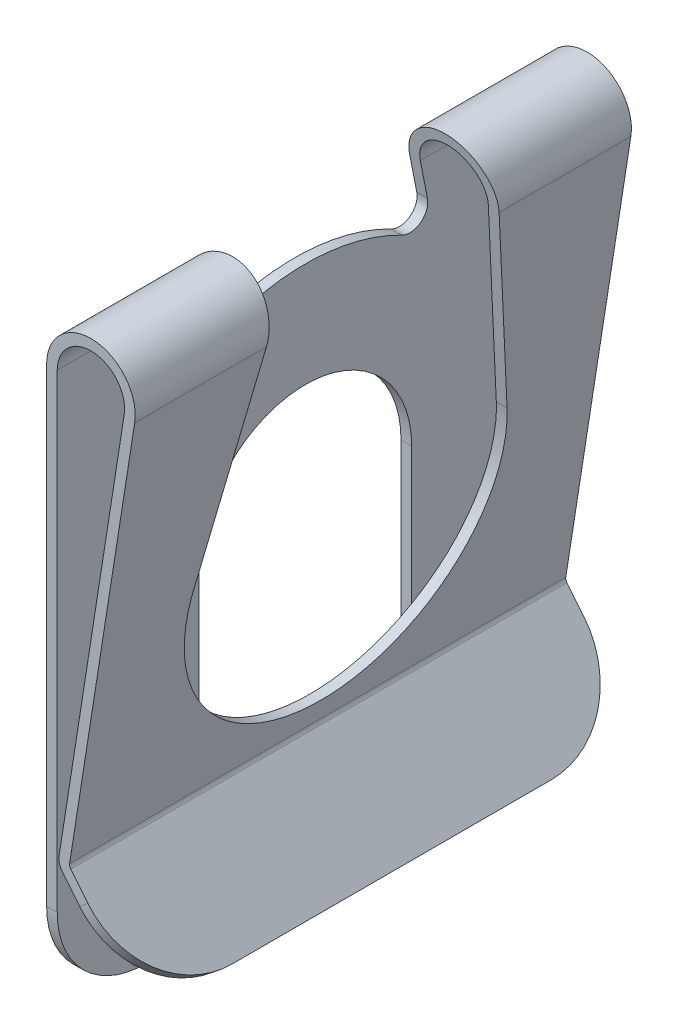
from build123d import *

# Parameters (mm, degrees)
BOSS_EXTRUDE1_DEPTH      = 14
BOSS_EXTRUDE1_DEPTH_BACK = 14
CUT_EXTRUDE1_DEPTH       = 0.6
CUT_EXTRUDE2_DEPTH       = 5.4
CUT_EXTRUDE3_DEPTH       = 5.4
CUT_EXTRUDE4_DEPTH       = 0.6
CUT_EXTRUDE5_DEPTH       = 0.6
CUT_EXTRUDE6_DEPTH       = 0.6
CUT_EXTRUDE7_DEPTH       = 0.6
CUT_EXTRUDE8_DEPTH       = 1.2
CUT_EXTRUDE8_DEPTH_BACK  = 1.2


with BuildPart() as part:
    # Sketch1 → Boss-Extrude1 (new, two sides: drawn at the far end of the back side and taken through both)
    with BuildSketch(Plane.XY.offset(-BOSS_EXTRUDE1_DEPTH_BACK)):
        with BuildLine():
            Line((0, 13.7), (0, -17.8))
            Line((0, -17.8), (0.6, -17.8))
            Line((0.6, -17.8), (0.6, 13.7))
            ThreePointArc((0.6, 13.7), (2.647893792, 15.594235314), (4.376976238, 13.405109849))
            Line((4.376976238, 13.405109849), (0.703859087, -9.974286111))
            ThreePointArc((0.703859087, -9.974286111), (0.724075997, -10.348603801), (0.895029628, -10.682216319))
            Line((0.895029628, -10.682216319), (5.036277977, -15.76853009))
            Line((5.036277977, -15.76853009), (5.501560288, -15.389699824))
            Line((5.501560288, -15.389699824), (1.360311939, -10.303386053))
            ThreePointArc((1.360311939, -10.303386053), (1.303327395, -10.19218188), (1.296588425, -10.067409316))
            Line((1.296588425, -10.067409316), (4.969705577, 13.311986643))
            ThreePointArc((4.969705577, 13.311986643), (2.694597095, 16.192414887), (0, 13.7))
        make_face()
    extrude(amount=BOSS_EXTRUDE1_DEPTH + BOSS_EXTRUDE1_DEPTH_BACK)

    # Sketch2 → Cut-Extrude1 (cut)
    with BuildSketch(Plane(origin=(0, 0, 0), x_dir=(0, 0, -1), z_dir=(1, 0, 0))):
        with BuildLine():
            Line((-6, 0), (-6, -17.8))
            Line((-6, -17.8), (6, -17.8))
            Line((6, -17.8), (6, 0))
            ThreePointArc((6, 0), (0, 6), (-6, 0))
        make_face()
    extrude(amount=CUT_EXTRUDE1_DEPTH, mode=Mode.SUBTRACT)

    # Sketch3 → Cut-Extrude2 (cut)
    with BuildSketch(Plane(origin=(0.6, 0, 0), x_dir=(0, 0, -1), z_dir=(1, 0, 0))):
        with BuildLine():
            Line((8.832410113, 1.728736995), (6, 16.2))
            Line((6, 16.2), (-6, 16.2))
            Line((-6, 16.2), (-8.832410113, 1.728736995))
            ThreePointArc((-8.832410113, 1.728736995), (0, -9), (8.832410113, 1.728736995))
        make_face()
    extrude(amount=CUT_EXTRUDE2_DEPTH, mode=Mode.SUBTRACT)

    # Sketch4 → Cut-Extrude3 (cut)
    with BuildSketch(Plane(origin=(0.6, 0, 0), x_dir=(0, 0, -1), z_dir=(1, 0, 0))):
        with BuildLine():
            Line((6.88858316, 11.660078132), (6, 16.2))
            Line((6, 16.2), (-6, 16.2))
            Line((-6, 16.2), (-6.88858316, 11.660078132))
            ThreePointArc((-6.88858316, 11.660078132), (-6.507772079, 10.668422424), (-5.449281397, 10.579004313))
            ThreePointArc((-5.449281397, 10.579004313), (2.9e-08, 11.9), (5.449281448, 10.579004287))
            ThreePointArc((5.449281448, 10.579004287), (6.507772102, 10.668422441), (6.88858316, 11.660078132))
        make_face()
    extrude(amount=-CUT_EXTRUDE3_DEPTH, mode=Mode.SUBTRACT)

    # Sketch5 → Cut-Extrude4 (cut)
    with BuildSketch(Plane(origin=(0, 0, 0), x_dir=(0, 0, -1), z_dir=(1, 0, 0))):
        with BuildLine():
            Line((-14, -17.8), (-9, -17.8))
            ThreePointArc((-9, -17.8), (-12.535533906, -16.335533906), (-14, -12.8))
            Line((-14, -12.8), (-14, -17.8))
        make_face()
    extrude(amount=CUT_EXTRUDE4_DEPTH, mode=Mode.SUBTRACT)

    # Sketch6 → Cut-Extrude5 (cut)
    with BuildSketch(Plane(origin=(0, 0, 0), x_dir=(0, 0, -1), z_dir=(1, 0, 0))):
        with BuildLine():
            Line((9, -17.8), (14, -17.8))
            Line((14, -17.8), (14, -12.8))
            ThreePointArc((14, -12.8), (12.535533906, -16.335533906), (9, -17.8))
        make_face()
    extrude(amount=CUT_EXTRUDE5_DEPTH, mode=Mode.SUBTRACT)

    # Sketch7 → Cut-Extrude6 (cut)
    with BuildSketch(Plane(origin=(0, 0, 0), x_dir=(0, 0, -1), z_dir=(1, 0, 0))):
        with BuildLine():
            Line((6, -17.8), (7, -17.8))
            ThreePointArc((7, -17.8), (6.292893219, -17.507106781), (6, -16.8))
            Line((6, -16.8), (6, -17.8))
        make_face()
    extrude(amount=CUT_EXTRUDE6_DEPTH, mode=Mode.SUBTRACT)

    # Sketch8 → Cut-Extrude7 (cut)
    with BuildSketch(Plane(origin=(0, 0, 0), x_dir=(0, 0, -1), z_dir=(1, 0, 0))):
        with BuildLine():
            Line((-7, -17.8), (-6, -17.8))
            Line((-6, -17.8), (-6, -16.8))
            ThreePointArc((-6, -16.8), (-6.292893219, -17.507106781), (-7, -17.8))
        make_face()
    extrude(amount=CUT_EXTRUDE7_DEPTH, mode=Mode.SUBTRACT)

    # Sketch9 → Cut-Extrude8 (cut, two sides: drawn at the far end of the back side and taken through both)
    with BuildSketch(Plane(origin=(-4.226709045, -3.441362969, 0), x_dir=(0, 0, -1), z_dir=(0.7754705184321754, 0.6313837779374231, 0)).offset(-CUT_EXTRUDE8_DEPTH_BACK)):
        with BuildLine():
            Line((-14, -10.380851015), (-19, -10.380851015))
            Line((-19, -10.380851015), (-19, -20.380851015))
            Line((-19, -20.380851015), (19, -20.380851015))
            Line((19, -20.380851015), (19, -10.380851015))
            Line((19, -10.380851015), (14, -10.380851015))
            ThreePointArc((14, -10.380851015), (12.535533906, -13.916384921), (9, -15.380851015))
            Line((9, -15.380851015), (-9, -15.380851015))
            ThreePointArc((-9, -15.380851015), (-12.535533906, -13.916384921), (-14, -10.380851015))
        make_face()
    extrude(amount=CUT_EXTRUDE8_DEPTH + CUT_EXTRUDE8_DEPTH_BACK, mode=Mode.SUBTRACT)


solid = part.part
